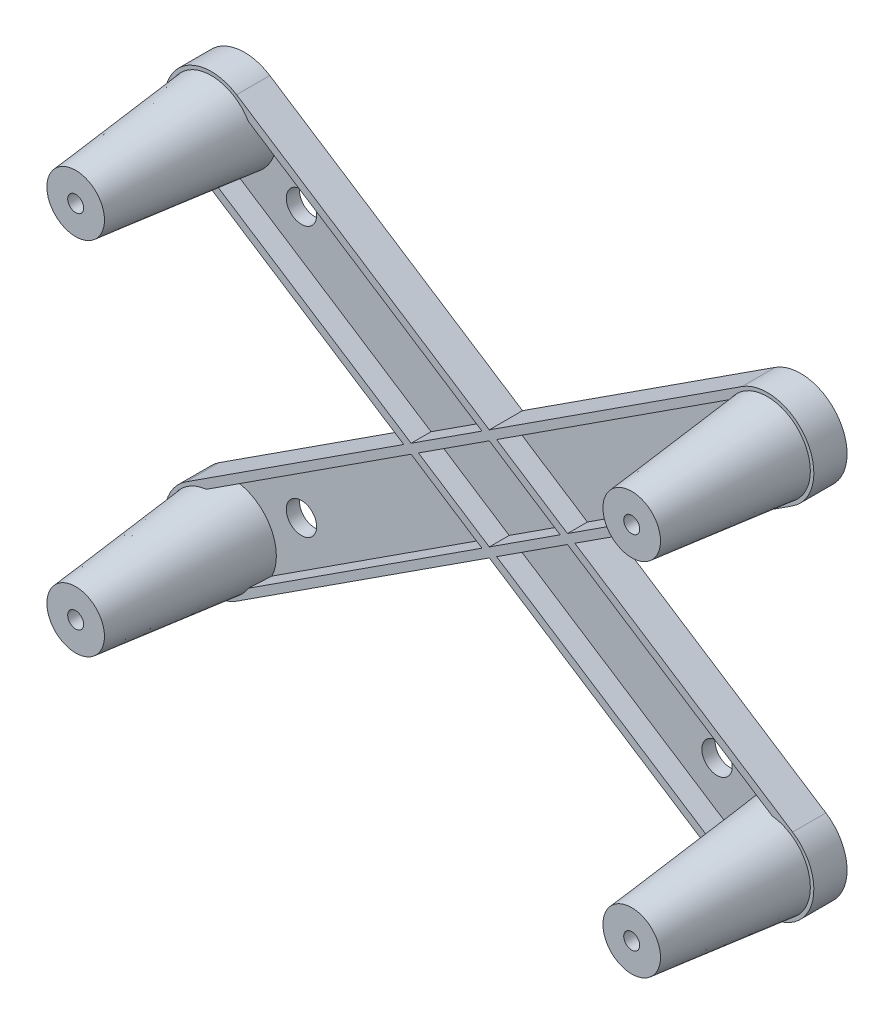
from build123d import *

# Parameters (mm, degrees)
BASE_DEPTH            = 2
SKETCH3_R             = 7
MOUNTING_BOSSES_DEPTH = 25.4
MOUNTING_BOSSES_TAPER = 6
RIBW_DEPTH            = 5
SKETCH6_R             = 2.286
MOUNTING_HOLES_DEPTH  = 3
SKETCH7_R             = 1.2
SCREW_HOLES_DEPTH     = 26.4


with BuildPart() as part:
    # Sketch2 → Base (new body)
    with BuildSketch(Plane.XY):
        with BuildLine():
            Line((3.808375995, 60.113352729), (87.458375995, 5.873352729))
            ThreePointArc((87.458375995, 5.873352729), (89.523352729, -3.808375995), (79.841624005, -5.873352729))
            Line((79.841624005, -5.873352729), (-3.808375995, 48.366647271))
            ThreePointArc((-3.808375995, 48.366647271), (-5.873352729, 58.048375995), (3.808375995, 60.113352729))
        make_face()
        with BuildLine():
            Line((87.458375995, 48.366647271), (3.808375995, -5.873352729))
            ThreePointArc((3.808375995, -5.873352729), (-5.873352729, -3.808375995), (-3.808375995, 5.873352729))
            Line((-3.808375995, 5.873352729), (79.841624005, 60.113352729))
            ThreePointArc((79.841624005, 60.113352729), (89.523352729, 58.048375995), (87.458375995, 48.366647271))
        make_face()
    extrude(amount=BASE_DEPTH)

    # Sketch3 → Mounting Bosses (add)
    with BuildSketch(Plane.XY):
        with Locations((0, 54.24)):
            Circle(SKETCH3_R)
        Circle(SKETCH3_R)
        with Locations((83.65, 0)):
            Circle(SKETCH3_R)
        with Locations((83.65, 54.24)):
            Circle(SKETCH3_R)
    extrude(amount=MOUNTING_BOSSES_DEPTH, taper=MOUNTING_BOSSES_TAPER)

    # Sketch5 → Ribw (add)
    with BuildSketch(Plane.XY):
        with BuildLine():
            Line((79.841624005, 60.113352729), (41.825, 35.462764731))
            Line((41.825, 35.462764731), (3.808375995, 60.113352729))
            ThreePointArc((3.808375995, 60.113352729), (-5.873352729, 58.048375995), (-3.808375995, 48.366647271))
            Line((-3.808375995, 48.366647271), (28.958623345, 27.12))
            Line((28.958623345, 27.12), (-3.808375995, 5.873352729))
            ThreePointArc((-3.808375995, 5.873352729), (-5.873352729, -3.808375995), (3.808375995, -5.873352729))
            Line((3.808375995, -5.873352729), (41.825, 18.777235269))
            Line((41.825, 18.777235269), (79.841624005, -5.873352729))
            ThreePointArc((79.841624005, -5.873352729), (89.523352729, -3.808375995), (87.458375995, 5.873352729))
            Line((87.458375995, 5.873352729), (54.691376655, 27.12))
            Line((54.691376655, 27.12), (87.458375995, 48.366647271))
            ThreePointArc((87.458375995, 48.366647271), (89.523352729, 58.048375995), (79.841624005, 60.113352729))
        make_face()
        with BuildLine():
            Line((80.494488461, 59.106492261), (42.927832285, 34.747670611))
            Line((42.927832285, 34.747670611), (53.58854437, 27.83509412))
            Line((53.58854437, 27.83509412), (86.805511539, 49.373507739))
            ThreePointArc((86.805511539, 49.373507739), (88.516492261, 57.395511539), (80.494488461, 59.106492261))
        make_face(mode=Mode.SUBTRACT)
        with BuildLine():
            Line((-3.155511539, 49.373507739), (30.06145563, 27.83509412))
            Line((30.06145563, 27.83509412), (40.722167715, 34.747670611))
            Line((40.722167715, 34.747670611), (3.155511539, 59.106492261))
            ThreePointArc((3.155511539, 59.106492261), (-4.866492261, 57.395511539), (-3.155511539, 49.373507739))
        make_face(mode=Mode.SUBTRACT)
        with BuildLine():
            Line((30.06145563, 26.40490588), (40.722167715, 19.492329389))
            Line((40.722167715, 19.492329389), (3.155511539, -4.866492261))
            ThreePointArc((3.155511539, -4.866492261), (-4.866492261, -3.155511539), (-3.155511539, 4.866492261))
            Line((-3.155511539, 4.866492261), (30.06145563, 26.40490588))
        make_face(mode=Mode.SUBTRACT)
        Polygon((31.164287915, 27.12), (41.825, 20.207423508), (52.485712085, 27.12), (41.825, 34.032576492), align=None, mode=Mode.SUBTRACT)
        with BuildLine():
            Line((42.927832285, 19.492329389), (80.494488461, -4.866492261))
            ThreePointArc((80.494488461, -4.866492261), (88.516492261, -3.155511539), (86.805511539, 4.866492261))
            Line((86.805511539, 4.866492261), (53.58854437, 26.40490588))
            Line((53.58854437, 26.40490588), (42.927832285, 19.492329389))
        make_face(mode=Mode.SUBTRACT)
    extrude(amount=RIBW_DEPTH)

    # Sketch6 → Mounting Holes (cut, through all)
    with BuildSketch(Plane.XY.offset(2)):
        with Locations((10.563469491, 6.849522835)):
            Circle(SKETCH6_R)
        with Locations((10.563469491, 47.390477165)):
            Circle(SKETCH6_R)
        with Locations((73.351093758, 47.562024213)):
            Circle(SKETCH6_R)
        with Locations((73.086530509, 6.849522835)):
            Circle(SKETCH6_R)
    extrude(amount=-MOUNTING_HOLES_DEPTH, mode=Mode.SUBTRACT)

    # Sketch7 → Screw Holes (cut, through all)
    with BuildSketch(Plane.XY.offset(25.4)):
        Circle(SKETCH7_R)
        with Locations((0, 54.24)):
            Circle(SKETCH7_R)
        with Locations((83.65, 54.24)):
            Circle(SKETCH7_R)
        with Locations((83.65, 0)):
            Circle(SKETCH7_R)
    extrude(amount=-SCREW_HOLES_DEPTH, mode=Mode.SUBTRACT)


solid = part.part
